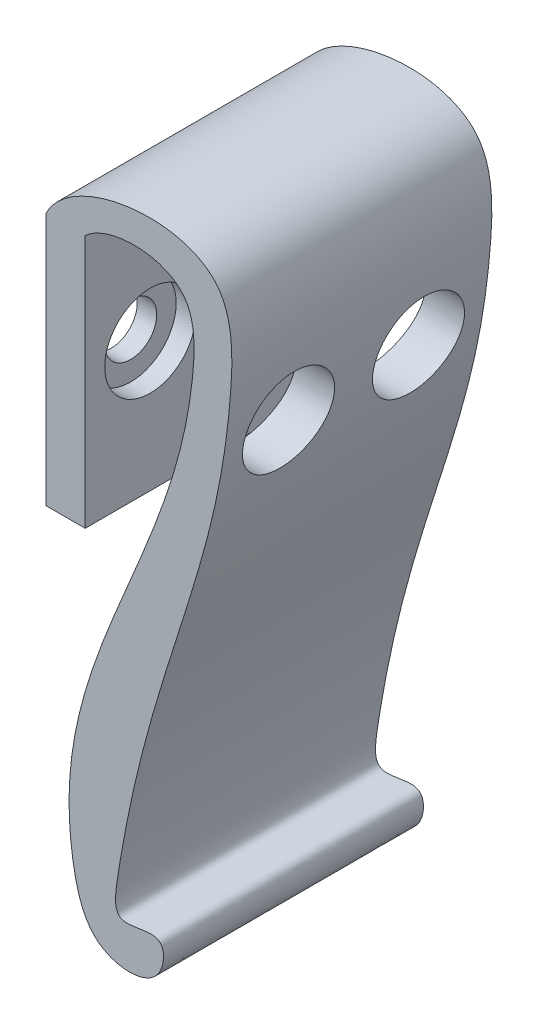
from build123d import *

# Parameters (mm, degrees)
SKETCH1_W               = 3
SKETCH1_H               = 19.499640592
BOSS_EXTRUDE1_DEPTH     = 20
SKETCH2_R               = 2
CUT_EXTRUDE1_DEPTH      = 20
SKETCH3_R               = 3.5
SKETCH3_R_2             = 2
CUT_EXTRUDE2_DEPTH      = 20
CUT_EXTRUDE2_DEPTH_BACK = 1.5


with BuildPart() as part:
    # Sketch1 → Boss-Extrude1 (new body)
    with BuildSketch(Plane.XY):
        with BuildLine():
            Line((0, 0), (-3, 0))
            add(Edge.make_bspline(
                [(0, 0), (1.755975858, 1.672729228), (8.496995786, 1.753790681), (8.316016773, -17.926447058), (-4.639803217, -30.159361532), (0.417828729, -47.662634668), (5.961333881, -47.543589746), (6.235510038, -43.113794788), (1.979404043, -45.141456413), (4.616461943, -25.816495667), (11.063247337, -17.21257273), (11.537329692, 5.728169145), (-1.160888513, 3.823667396), (-3, 0)],
                knots=[0, 0, 0, 0, 0.062551543, 0.100419617, 0.404902243, 0.445150784, 0.47842361, 0.493843888, 0.517517407, 0.537515349, 0.834560094, 0.886833813, 1, 1, 1, 1], degree=3))
        make_face()
        with Locations((-1.5, -9.749820296)):
            Rectangle(SKETCH1_W, SKETCH1_H)
    extrude(amount=BOSS_EXTRUDE1_DEPTH)

    # Sketch2 → Cut-Extrude1 (cut)
    with BuildSketch(Plane.ZY.offset(3)):
        with Locations((5, -9.499640592)):
            Circle(SKETCH2_R)
        with Locations((15, -9.499640592)):
            Circle(SKETCH2_R)
    extrude(amount=-CUT_EXTRUDE1_DEPTH, mode=Mode.SUBTRACT)

    # Sketch3 → Cut-Extrude2 (cut, two sides)
    with BuildSketch(Plane(origin=(0, 0, 0), x_dir=(0, 0, -1), z_dir=(1, 0, 0))) as cut_extrude2_sk:
        with Locations((-5, -9.499640592)):
            Circle(SKETCH3_R)
        with Locations((-5, -9.499640592)):
            Circle(SKETCH3_R_2, mode=Mode.SUBTRACT)
        with Locations((-15, -9.499640592)):
            Circle(SKETCH3_R)
    extrude(amount=CUT_EXTRUDE2_DEPTH, mode=Mode.SUBTRACT)
    extrude(cut_extrude2_sk.sketch, amount=-CUT_EXTRUDE2_DEPTH_BACK, mode=Mode.SUBTRACT)


solid = part.part
